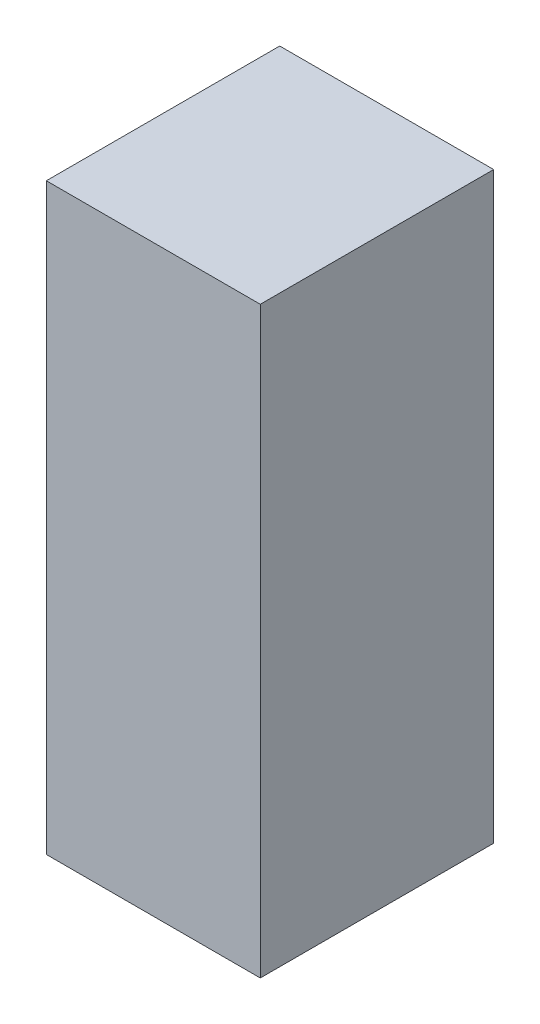
from build123d import *

# Parameters (mm, degrees)
SKETCH1_W           = 558.8
SKETCH1_H           = 609.6
BOSS_EXTRUDE1_DEPTH = 1524


with BuildPart() as part:
    # Sketch1 → Boss-Extrude1 (new body)
    with BuildSketch(Plane(origin=(0, 0, 0), x_dir=(1, 0, 0), z_dir=(0, 1, 0))):
        Rectangle(SKETCH1_W, SKETCH1_H)
    extrude(amount=BOSS_EXTRUDE1_DEPTH)


solid = part.part
